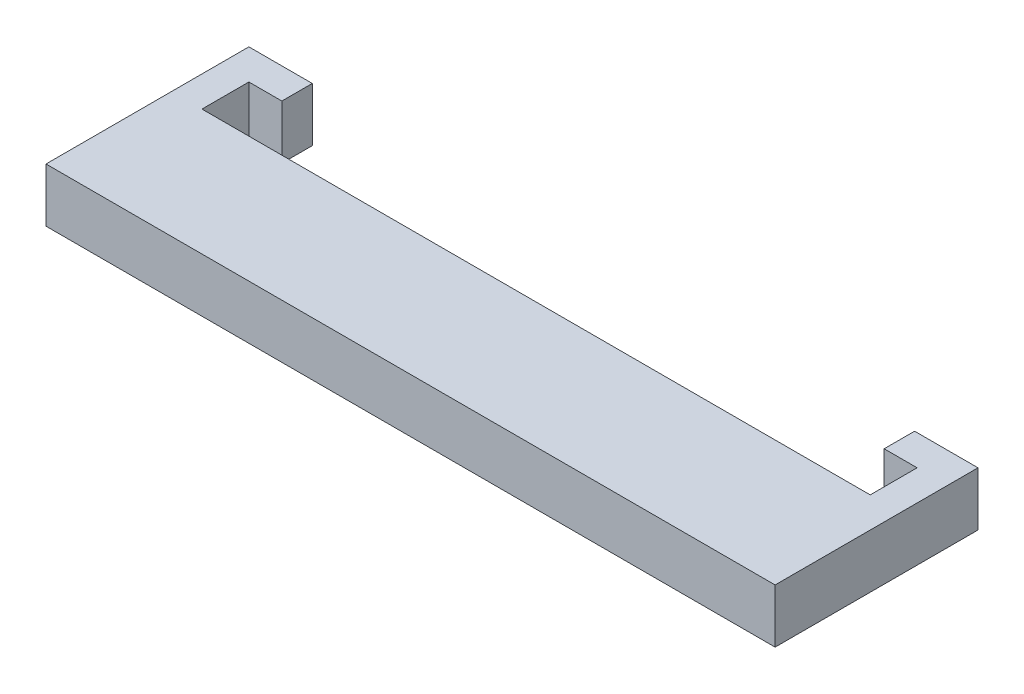
from build123d import *

# Parameters (mm, degrees)
BOSS_EXTRUDE1_DEPTH = 8.5


with BuildPart() as part:
    # Sketch1 → Boss-Extrude1 (new body)
    with BuildSketch(Plane(origin=(0, 0, 0), x_dir=(1, 0, 0), z_dir=(0, 1, 0))):
        Polygon((-0.2, 7.2), (5, 7.2), (5, 12), (-5, 12), (-5, -20), (52.5, -20), (52.5, -0.2), (-0.2, -0.2), align=None)
        Polygon((100, 12), (100, 7.2), (105.2, 7.2), (105.2, -0.2), (52.5, -0.2), (52.5, -20), (110, -20), (110, 12), align=None)
    extrude(amount=BOSS_EXTRUDE1_DEPTH)


solid = part.part
